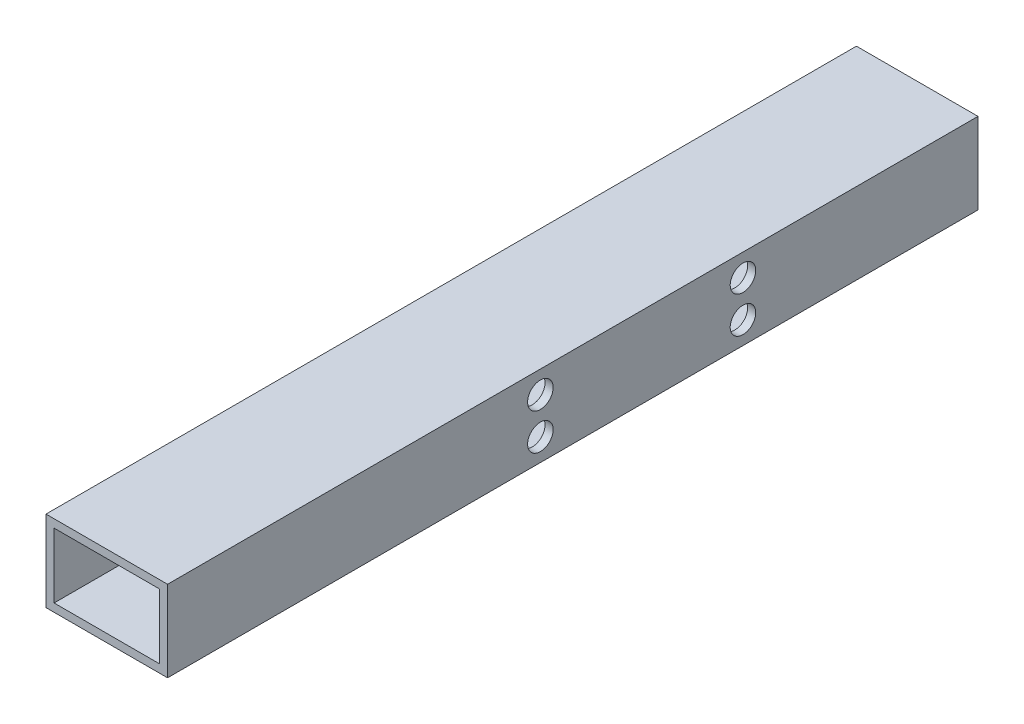
from build123d import *

# Parameters (mm, degrees)
SKETCH_1_W          = 30
SKETCH_1_H          = 20
SKETCH_1_W_2        = 26
SKETCH_1_H_2        = 16
EXTRUDE_1_DEPTH     = 200
SKETCH_2_R          = 1.6
CUT_EXTRUDE_1_DEPTH = 203.484567313
SKETCH_2_3_R        = 3.15
SKETCH_2_3_R_2      = 1.6
CUT_EXTRUDE_2_DEPTH = 3


with BuildPart() as part:
    # Эскиз1 → Бобышка-Вытянуть1 (new body)
    with BuildSketch(Plane.XY):
        Rectangle(SKETCH_1_W, SKETCH_1_H)
        Rectangle(SKETCH_1_W_2, SKETCH_1_H_2, mode=Mode.SUBTRACT)
    extrude(amount=EXTRUDE_1_DEPTH)

    # Эскиз2 → Вырез-Вытянуть1 (cut, through all)
    with BuildSketch(Plane(origin=(15, 0, 0), x_dir=(0, 0, -1), z_dir=(1, 0, 0))):
        with Locations((-108, 4.5)):
            Circle(SKETCH_2_R)
        with Locations((-108, -4.5)):
            Circle(SKETCH_2_R)
        with Locations((-58, -4.5)):
            Circle(SKETCH_2_R)
        with Locations((-58, 4.5)):
            Circle(SKETCH_2_R)
    extrude(amount=-CUT_EXTRUDE_1_DEPTH, mode=Mode.SUBTRACT)

    # Эскиз2<3> → Вырез-Вытянуть2 (cut)
    # profile 1 of 4: a face of its own
    with BuildSketch(Plane(origin=(15, 0, 0), x_dir=(0, 0, -1), z_dir=(1, 0, 0))):
        with Locations((-108, -4.5)):
            Circle(SKETCH_2_3_R)
        with Locations((-108, -4.5)):
            Circle(SKETCH_2_3_R_2, mode=Mode.SUBTRACT)
    # profile 2 of 4: a face of its own
    with BuildSketch(Plane(origin=(15, 0, 0), x_dir=(0, 0, -1), z_dir=(1, 0, 0))):
        with Locations((-108, 4.5)):
            Circle(SKETCH_2_3_R)
        with Locations((-108, 4.5)):
            Circle(SKETCH_2_3_R_2, mode=Mode.SUBTRACT)
    # profile 3 of 4: a face of its own
    with BuildSketch(Plane(origin=(15, 0, 0), x_dir=(0, 0, -1), z_dir=(1, 0, 0))):
        with Locations((-58, -4.5)):
            Circle(SKETCH_2_3_R)
        with Locations((-58, -4.5)):
            Circle(SKETCH_2_3_R_2, mode=Mode.SUBTRACT)
    # profile 4 of 4: a face of its own
    with BuildSketch(Plane(origin=(15, 0, 0), x_dir=(0, 0, -1), z_dir=(1, 0, 0))):
        with Locations((-58, 4.5)):
            Circle(SKETCH_2_3_R)
        with Locations((-58, 4.5)):
            Circle(SKETCH_2_3_R_2, mode=Mode.SUBTRACT)
    extrude(amount=-CUT_EXTRUDE_2_DEPTH, mode=Mode.SUBTRACT)


solid = part.part
